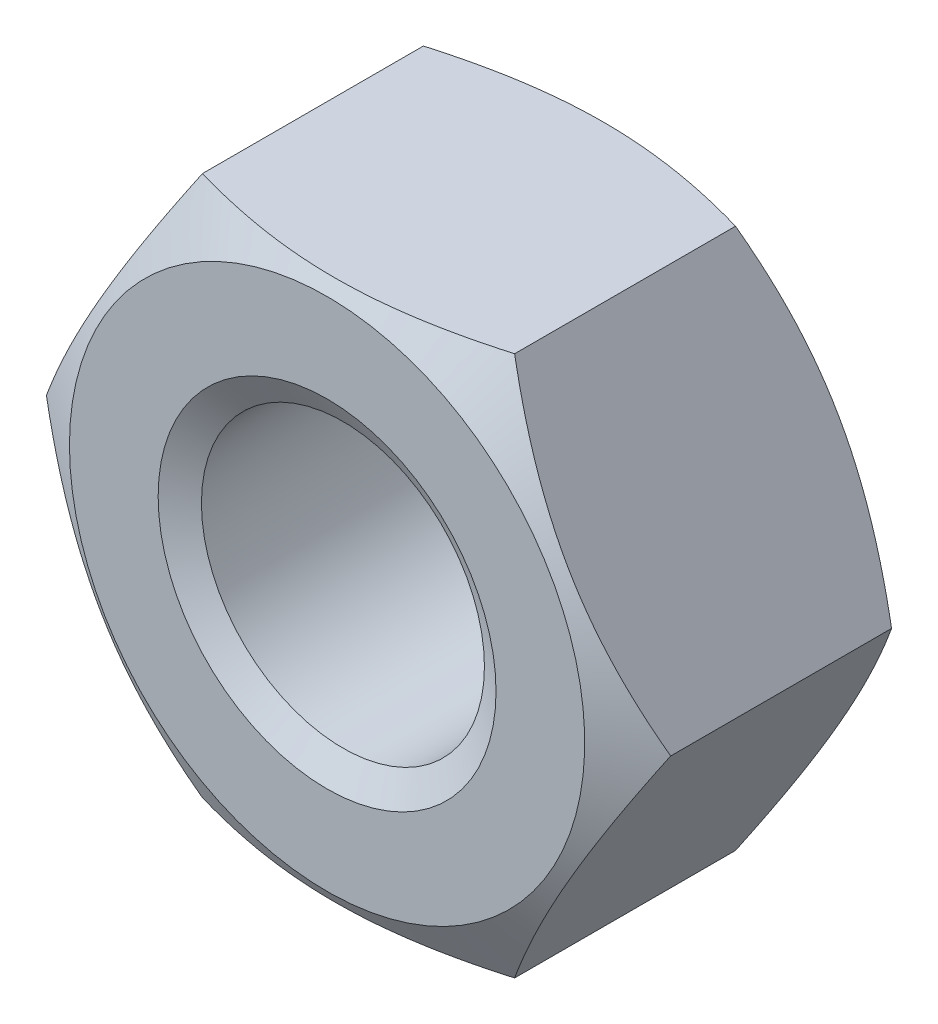
from build123d import *

# Parameters (mm, degrees)
SKETCH1_R               = 4.188
BASENUT_DEPTH           = 8.4
ENDCHAMFER_SIZE         = 0.812
ENDCHAMFER_SIZE2        = 0.468808419
ENDCHAMFER_PART_2_SIZE  = 0.812
ENDCHAMFER_PART_2_SIZE2 = 0.468808419


with BuildPart() as part:
    # Sketch1 → BaseNut (new body)
    with BuildSketch(Plane.XY):
        Polygon((9.237604307, 0), (4.618802154, 8), (-4.618802154, 8), (-9.237604307, 0), (-4.618802154, -8), (4.618802154, -8), align=None)
        Circle(SKETCH1_R, mode=Mode.SUBTRACT)
    extrude(amount=-BASENUT_DEPTH)

    # Sketch2 → Double-Chamfer (revolve, cut)
    with BuildSketch(Plane(origin=(0, 0, 0), x_dir=(1, 0, 0), z_dir=(0, 1, 0))):
        Polygon((-9.237604307, 8.4), (-7.625, 8.4), (-9.237604307, 7.468962469), align=None)
        Polygon((-9.237604307, 0.931037531), (-9.237604307, 0), (-7.625, 0), align=None)
    revolve(axis=Axis((0, 0, -3.375940562), (0, 0, 1)), mode=Mode.SUBTRACT)

    # EndChamfer
    endchamfer_edges = [part.edges().sort_by_distance(p)[0] for p in [
        (-4.188, 0, -8.4),
    ]]
    endchamfer_side = [part.faces().sort_by_distance(p)[0] for p in [
        (-4.188, 0, -4.2),
    ]]
    chamfer(endchamfer_edges, length=ENDCHAMFER_SIZE, length2=ENDCHAMFER_SIZE2, reference=endchamfer_side[0])

    # EndChamfer part 2
    endchamfer_part_2_edges = [part.edges().sort_by_distance(p)[0] for p in [
        (-4.188, 0, 0),
    ]]
    endchamfer_part_2_side = [part.faces().sort_by_distance(p)[0] for p in [
        (7.409332432, 0, 0),
    ]]
    chamfer(endchamfer_part_2_edges, length=ENDCHAMFER_PART_2_SIZE, length2=ENDCHAMFER_PART_2_SIZE2, reference=endchamfer_part_2_side[0])


solid = part.part
